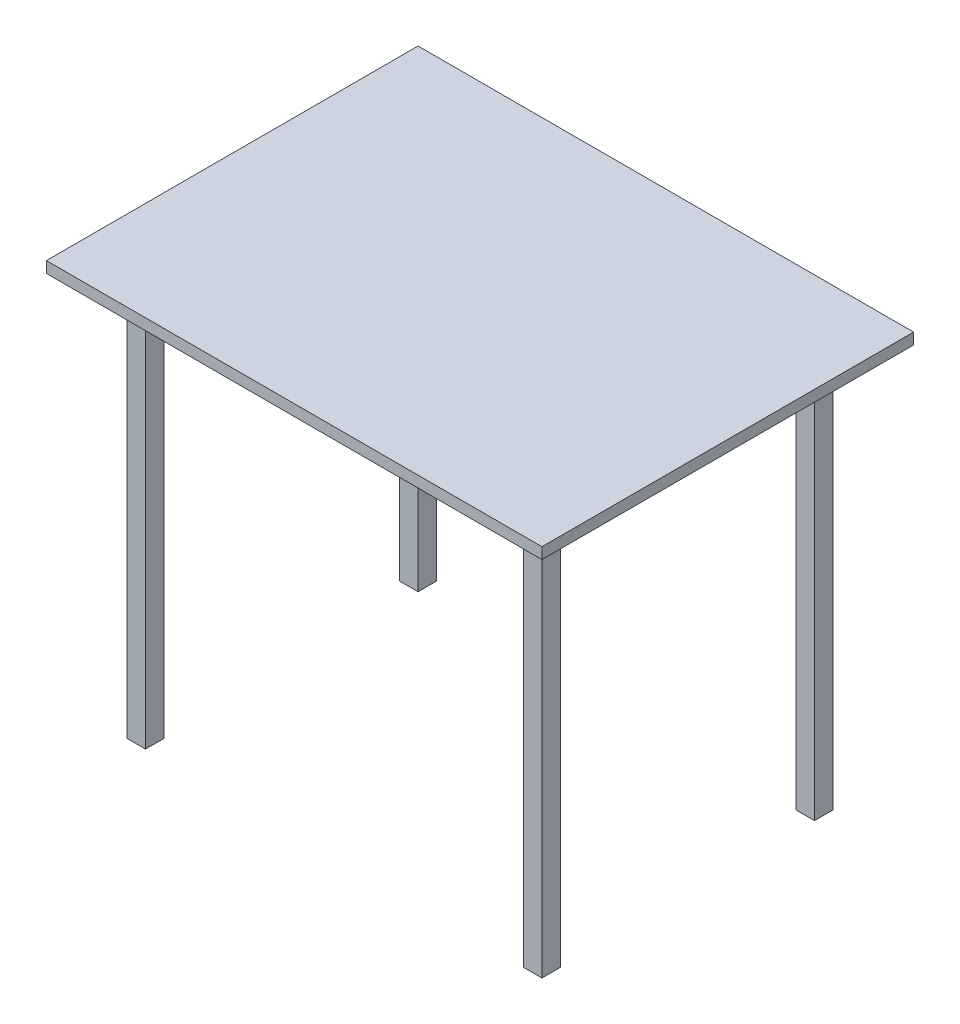
from build123d import *

# Parameters (mm, degrees)
SKETCH_1_W      = 800
SKETCH_1_H      = 600
EXTRUDE_1_DEPTH = 18
SKETCH_2_W      = 30
SKETCH_2_H      = 30
EXTRUDE_2_DEPTH = 650


with BuildPart() as part:
    # Эскиз1 → Бобышка-Вытянуть1 (new body)
    with BuildSketch(Plane(origin=(0, 0, 0), x_dir=(1, 0, 0), z_dir=(0, 1, 0))):
        Rectangle(SKETCH_1_W, SKETCH_1_H)
    extrude(amount=EXTRUDE_1_DEPTH)

    # Эскиз2 → Бобышка-Вытянуть2 (add)
    with BuildSketch(Plane.XZ):
        with Locations((-320, 220)):
            Rectangle(SKETCH_2_W, SKETCH_2_H)
        with Locations((320, 220)):
            Rectangle(SKETCH_2_W, SKETCH_2_H)
        with Locations((320, -220)):
            Rectangle(SKETCH_2_W, SKETCH_2_H)
        with Locations((-320, -220)):
            Rectangle(SKETCH_2_W, SKETCH_2_H)
    extrude(amount=EXTRUDE_2_DEPTH)


solid = part.part
